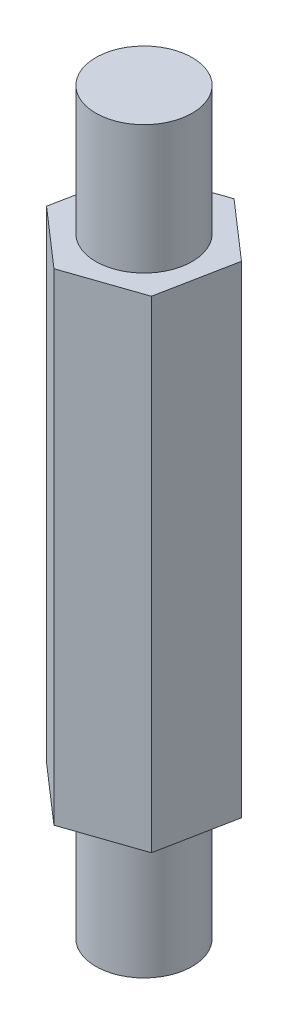
from build123d import *

# Parameters (mm, degrees)
BOSS_EXTRUDE1_DEPTH = 15
SKETCH2_R           = 1.5
BOSS_EXTRUDE2_DEPTH = 4
SKETCH3_R           = 1.5
BOSS_EXTRUDE3_DEPTH = 4


with BuildPart() as part:
    # Sketch1 → Boss-Extrude1 (new body)
    with BuildSketch(Plane(origin=(0, 0, 0), x_dir=(1, 0, 0), z_dir=(0, 1, 0))):
        Polygon((1.800179217, -1.569235172), (2.259087132, 0.774383347), (0.458907915, 2.343618519), (-1.800179217, 1.569235172), (-2.259087132, -0.774383347), (-0.458907915, -2.343618519), align=None)
    extrude(amount=BOSS_EXTRUDE1_DEPTH)

    # Sketch2 → Boss-Extrude2 (add)
    with BuildSketch(Plane(origin=(0, 15, 0), x_dir=(1, 0, 0), z_dir=(0, 1, 0))):
        Circle(SKETCH2_R)
    extrude(amount=BOSS_EXTRUDE2_DEPTH)

    # Sketch3 → Boss-Extrude3 (add)
    with BuildSketch(Plane.XZ):
        Circle(SKETCH3_R)
    extrude(amount=BOSS_EXTRUDE3_DEPTH)


solid = part.part
